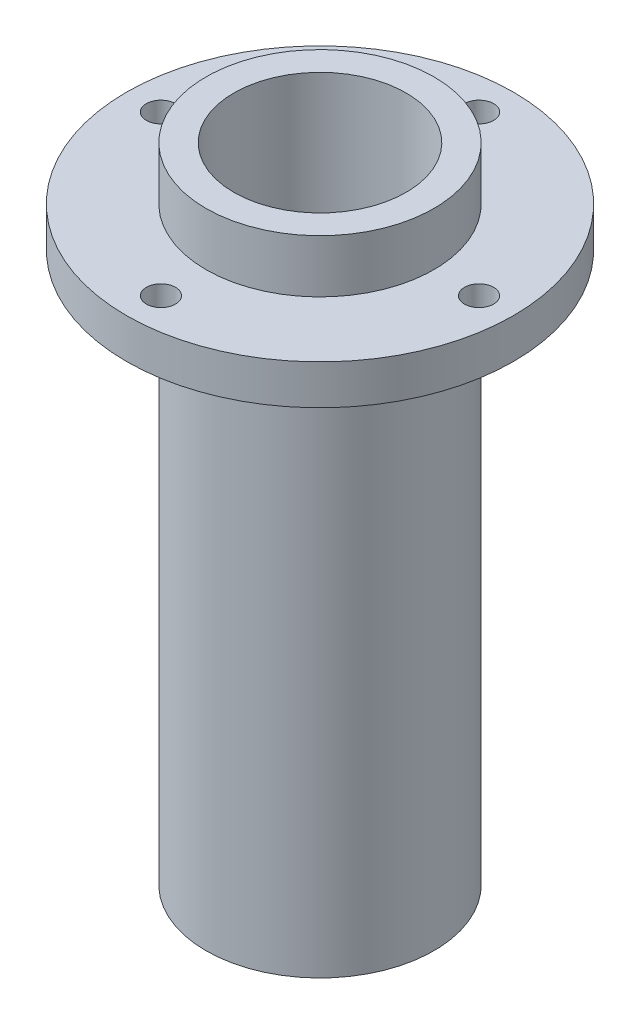
from build123d import *

# Parameters (mm, degrees)
CHAMFER1_SIZE      = 0.5
CUT_EXTRUDE1_REACH = 46.5
SKETCH2_R          = 1.1
SKETCH3_R          = 6.5
CUT_EXTRUDE2_DEPTH = 38


with BuildPart() as part:
    # Sketch1 → Revolve1 (revolve)
    with BuildSketch(Plane.XY):
        Polygon((-8.6, 20.75), (0, 20.75), (0, -20.75), (-6.6, -20.75), (-6.6, -27.75), (-8.6, -27.75), (-8.6, 13.75), (-14.6, 13.75), (-14.6, 16.75), (-8.6, 16.75), align=None)
    revolve(axis=Axis((0, 20.75, 0), (0, -1, 0)))

    # Chamfer1
    chamfer1_edges = [part.edges().sort_by_distance(p)[0] for p in [
        (6.6, -27.75, 0),
    ]]
    chamfer(chamfer1_edges, length=CHAMFER1_SIZE)

    # Sketch2 → Cut-Extrude1 (cut, up to next)
    with BuildSketch(Plane(origin=(0, 16.75, 0), x_dir=(1, 0, 0), z_dir=(0, 1, 0)), mode=Mode.PRIVATE) as cut_extrude1_sk1:
        with Locations((0, 12)):
            Circle(SKETCH2_R)
    cut_extrude1_tool1 = extrude(cut_extrude1_sk1.sketch, amount=-CUT_EXTRUDE1_REACH, mode=Mode.PRIVATE) & part.part
    add(cut_extrude1_tool1.solids().sort_by_distance((0, 16.75, -12))[0], mode=Mode.SUBTRACT)
    # Sketch2 → Cut-Extrude1 (cut, up to next)
    with BuildSketch(Plane(origin=(0, 16.75, 0), x_dir=(1, 0, 0), z_dir=(0, 1, 0)), mode=Mode.PRIVATE) as cut_extrude1_sk2:
        with Locations((12, 0)):
            Circle(SKETCH2_R)
    cut_extrude1_tool2 = extrude(cut_extrude1_sk2.sketch, amount=-CUT_EXTRUDE1_REACH, mode=Mode.PRIVATE) & part.part
    add(cut_extrude1_tool2.solids().sort_by_distance((12, 16.75, 0))[0], mode=Mode.SUBTRACT)
    # Sketch2 → Cut-Extrude1 (cut, up to next)
    with BuildSketch(Plane(origin=(0, 16.75, 0), x_dir=(1, 0, 0), z_dir=(0, 1, 0)), mode=Mode.PRIVATE) as cut_extrude1_sk3:
        with Locations((0, -12)):
            Circle(SKETCH2_R)
    cut_extrude1_tool3 = extrude(cut_extrude1_sk3.sketch, amount=-CUT_EXTRUDE1_REACH, mode=Mode.PRIVATE) & part.part
    add(cut_extrude1_tool3.solids().sort_by_distance((0, 16.75, 12))[0], mode=Mode.SUBTRACT)
    # Sketch2 → Cut-Extrude1 (cut, up to next)
    with BuildSketch(Plane(origin=(0, 16.75, 0), x_dir=(1, 0, 0), z_dir=(0, 1, 0)), mode=Mode.PRIVATE) as cut_extrude1_sk4:
        with Locations((-12, 0)):
            Circle(SKETCH2_R)
    cut_extrude1_tool4 = extrude(cut_extrude1_sk4.sketch, amount=-CUT_EXTRUDE1_REACH, mode=Mode.PRIVATE) & part.part
    add(cut_extrude1_tool4.solids().sort_by_distance((-12, 16.75, 0))[0], mode=Mode.SUBTRACT)

    # Sketch3 → Cut-Extrude2 (cut)
    with BuildSketch(Plane(origin=(0, 20.75, 0), x_dir=(1, 0, 0), z_dir=(0, 1, 0))):
        Circle(SKETCH3_R)
    extrude(amount=-CUT_EXTRUDE2_DEPTH, mode=Mode.SUBTRACT)


solid = part.part
